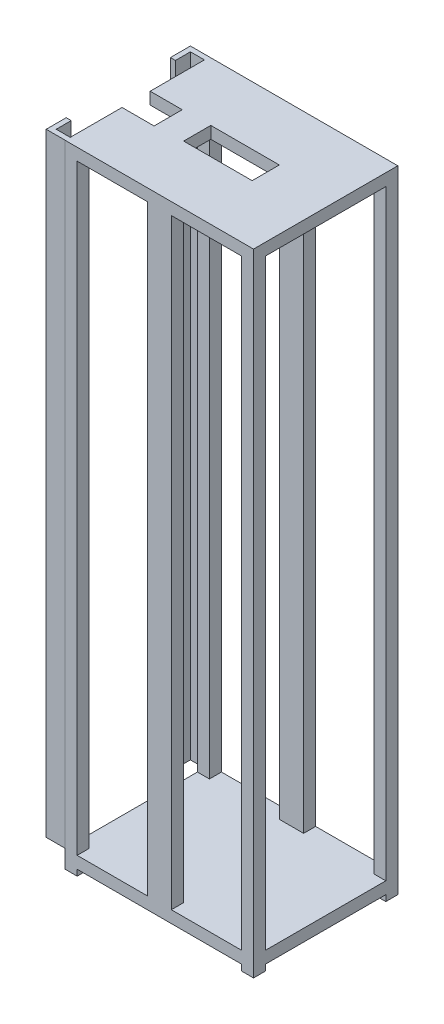
from build123d import *

# Parameters (mm, degrees)
SKETCH1_W            = 940
SKETCH1_H            = 720
BOSS_EXTRUDE1_DEPTH  = 60
SKETCH2_W            = 60
SKETCH2_H            = 60
BOSS_EXTRUDE2_DEPTH  = 3000
SKETCH3_W            = 60
SKETCH3_H            = 60
BOSS_EXTRUDE3_DEPTH  = 30
SKETCH4_W            = 940
SKETCH4_H            = 720
BOSS_EXTRUDE4_DEPTH  = 60
SKETCH5_W            = 120
SKETCH5_H            = 60
BOSS_EXTRUDE5_DEPTH  = 3120
SKETCH6_W            = 341.958021848
SKETCH6_H            = 135.576899716
CUT_EXTRUDE1_DEPTH   = 60
SKETCH8_R            = 17
SKETCH8_R_2          = 7
BOSS_EXTRUDE9_DEPTH  = 70
BOSS_EXTRUDE10_DEPTH = 3060
SKETCH15_W           = 159.933409955
SKETCH15_H           = 140.448340587
CUT_EXTRUDE2_DEPTH   = 60


with BuildPart() as part:
    # Sketch1 → Boss-Extrude1 (new body)
    with BuildSketch(Plane(origin=(0, 0, 0), x_dir=(1, 0, 0), z_dir=(0, 1, 0))):
        Rectangle(SKETCH1_W, SKETCH1_H)
    extrude(amount=BOSS_EXTRUDE1_DEPTH)

    # Sketch2 → Boss-Extrude2 (add)
    with BuildSketch(Plane(origin=(0, 60, 0), x_dir=(1, 0, 0), z_dir=(0, 1, 0))):
        with Locations((-440, 330)):
            Rectangle(SKETCH2_W, SKETCH2_H)
        with Locations((440, 330)):
            Rectangle(SKETCH2_W, SKETCH2_H)
        with Locations((440, -330)):
            Rectangle(SKETCH2_W, SKETCH2_H)
        with Locations((-440, -330)):
            Rectangle(SKETCH2_W, SKETCH2_H)
    extrude(amount=BOSS_EXTRUDE2_DEPTH)

    # Sketch3 → Boss-Extrude3 (add)
    with BuildSketch(Plane.XZ):
        with Locations((-440, 330)):
            Rectangle(SKETCH3_W, SKETCH3_H)
        with Locations((-440, -330)):
            Rectangle(SKETCH3_W, SKETCH3_H)
        with Locations((440, 330)):
            Rectangle(SKETCH3_W, SKETCH3_H)
        with Locations((440, -330)):
            Rectangle(SKETCH3_W, SKETCH3_H)
    extrude(amount=BOSS_EXTRUDE3_DEPTH)

    # Sketch4 → Boss-Extrude4 (add)
    with BuildSketch(Plane(origin=(0, 3060, 0), x_dir=(1, 0, 0), z_dir=(0, 1, 0))):
        Rectangle(SKETCH4_W, SKETCH4_H)
    extrude(amount=BOSS_EXTRUDE4_DEPTH)

    # Sketch5 → Boss-Extrude5 (add)
    with BuildSketch(Plane(origin=(0, 0, 0), x_dir=(1, 0, 0), z_dir=(0, 1, 0))):
        with Locations((0, 330)):
            Rectangle(SKETCH5_W, SKETCH5_H)
        with Locations((0, -330)):
            Rectangle(SKETCH5_W, SKETCH5_H)
    extrude(amount=BOSS_EXTRUDE5_DEPTH)

    # Sketch6 → Cut-Extrude1 (cut)
    with BuildSketch(Plane(origin=(0, 3120, 0), x_dir=(1, 0, 0), z_dir=(0, 1, 0))):
        Rectangle(SKETCH6_W, SKETCH6_H)
    extrude(amount=-CUT_EXTRUDE1_DEPTH, mode=Mode.SUBTRACT)

    # Sketch8 → Boss-Extrude9 (add)
    with BuildSketch(Plane.XZ.offset(-3060)):
        with Locations((365, 12)):
            Circle(SKETCH8_R)
        with Locations((365, 12)):
            Circle(SKETCH8_R_2, mode=Mode.SUBTRACT)
        with Locations((365, -60)):
            Circle(SKETCH8_R)
        with Locations((365, -60)):
            Circle(SKETCH8_R_2, mode=Mode.SUBTRACT)
        with Locations((365, -24)):
            Circle(SKETCH8_R)
        with Locations((365, -24)):
            Circle(SKETCH8_R_2, mode=Mode.SUBTRACT)
    extrude(amount=BOSS_EXTRUDE9_DEPTH)

    # Sketch13 → Boss-Extrude10 (add)
    with BuildSketch(Plane(origin=(0, 3120, 0), x_dir=(1, 0, 0), z_dir=(0, 1, 0))):
        Polygon((-435.683556983, 360), (-565, 360), (-565, 260), (-540, 260), (-540, 335), (-435.683556983, 335), align=None)
        Polygon((-435.683556983, -359.538961542), (-565, -359.538961542), (-565, -259.538961542), (-540, -259.538961542), (-540, -334.538961542), (-435.683556983, -334.538961542), align=None)
    extrude(amount=-BOSS_EXTRUDE10_DEPTH)

    # Sketch15 → Cut-Extrude2 (cut)
    with BuildSketch(Plane(origin=(0, 3120, 0), x_dir=(1, 0, 0), z_dir=(0, 1, 0))):
        with Locations((-390.033295023, -5.90994298)):
            Rectangle(SKETCH15_W, SKETCH15_H)
    extrude(amount=-CUT_EXTRUDE2_DEPTH, mode=Mode.SUBTRACT)


solid = part.part
